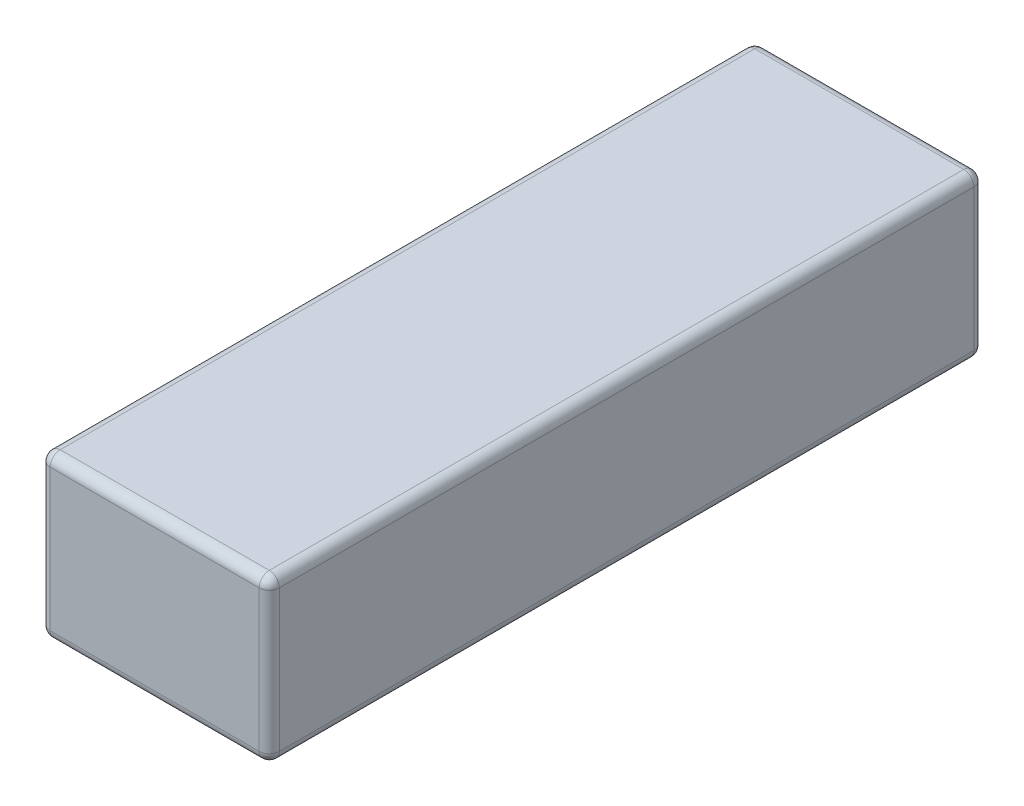
from build123d import *

# Parameters (mm, degrees)
CROQUIS1_W              = 34
CROQUIS1_H              = 106
SALIENTE_EXTRUIR1_DEPTH = 24
REDONDEO1_R             = 1.5


with BuildPart() as part:
    # Croquis1 → Saliente-Extruir1 (new body)
    with BuildSketch(Plane(origin=(0, 0, 0), x_dir=(1, 0, 0), z_dir=(0, 1, 0))):
        Rectangle(CROQUIS1_W, CROQUIS1_H)
    extrude(amount=SALIENTE_EXTRUIR1_DEPTH)

    # Redondeo1
    redondeo1_edges = [part.edges().sort_by_distance(p)[0] for p in [
        (17, 24, 0),
        (0, 24, -53),
        (-17, 24, 0),
        (0, 0, -53),
        (17, 0, 0),
        (0, 0, 53),
        (-17, 0, 0),
        (-17, 12, -53),
        (17, 12, -53),
        (17, 12, 53),
        (-17, 12, 53),
        (0, 24, 53),
    ]]
    fillet(redondeo1_edges, radius=REDONDEO1_R)


solid = part.part
